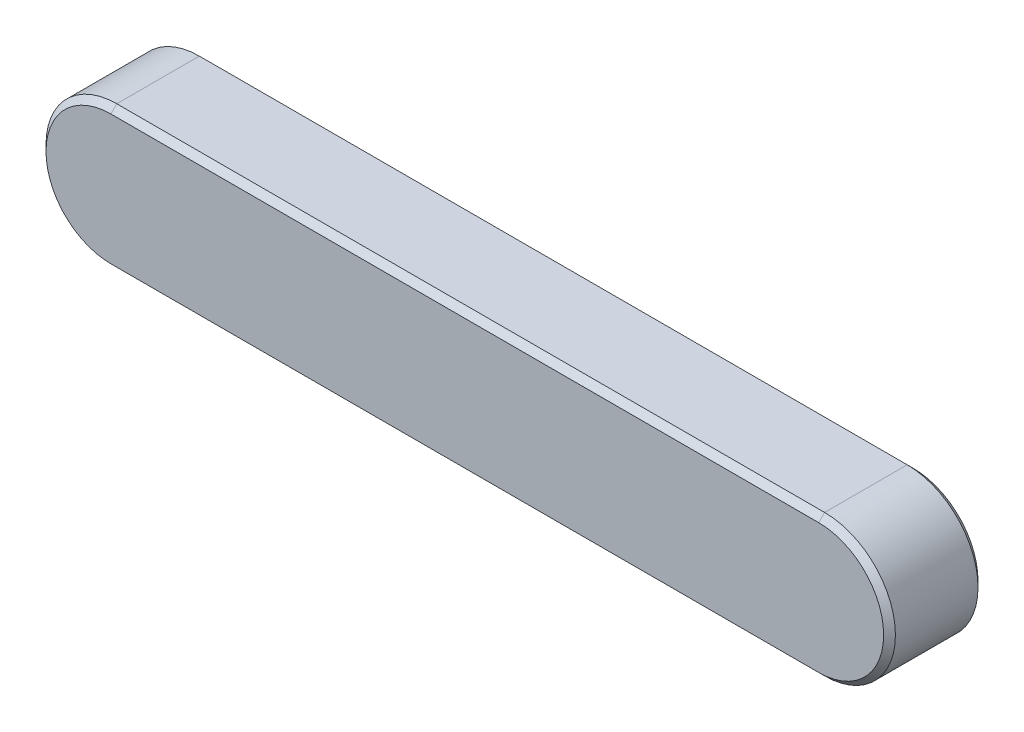
from build123d import *

# Parameters (mm, degrees)
EXTRUDE1_DEPTH = 4
CHAMFER1_SIZE  = 0.25


with BuildPart() as part:
    # Sketch1 → Extrude1 (new body)
    with BuildSketch(Plane.XY):
        with BuildLine():
            Line((0, 3), (-30, 3))
            ThreePointArc((-30, 3), (-33, 0), (-30, -3))
            Line((-30, -3), (0, -3))
            ThreePointArc((0, -3), (3, 0), (0, 3))
        make_face()
    extrude(amount=EXTRUDE1_DEPTH)

    # Chamfer1
    chamfer1_edges = [part.edges().sort_by_distance(p)[0] for p in [
        (-33, 0, 4),
        (-15, -3, 4),
        (3, 0, 4),
        (-15, -3, 0),
        (-33, 0, 0),
        (-15, 3, 0),
        (3, 0, 0),
        (-15, 3, 4),
    ]]
    chamfer(chamfer1_edges, length=CHAMFER1_SIZE)


solid = part.part
